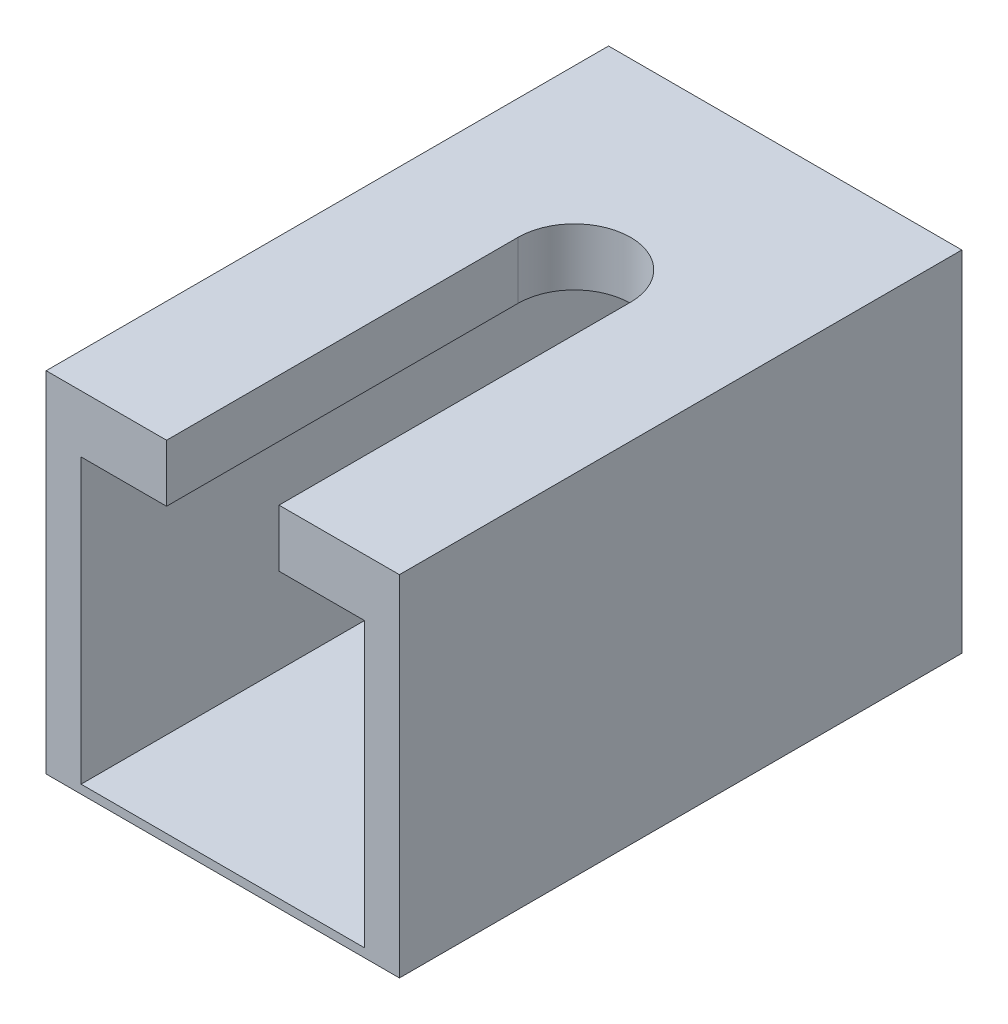
from build123d import *

# Parameters (mm, degrees)
SKETCH1_W           = 15.95500004
SKETCH1_H           = 15.775635
SKETCH1_W_2         = 12.8
SKETCH1_H_2         = 12.8
BOSS_EXTRUDE1_DEPTH = 12.7
CUT_EXTRUDE1_DEPTH  = 12.7


with BuildPart() as part:
    # Sketch1 → Boss-Extrude1 (new body, symmetric)
    with BuildSketch(Plane.XY):
        with Locations((0, 1.0956925)):
            Rectangle(SKETCH1_W, SKETCH1_H)
        Rectangle(SKETCH1_W_2, SKETCH1_H_2, mode=Mode.SUBTRACT)
    extrude(amount=BOSS_EXTRUDE1_DEPTH, both=True)

    # Sketch2 → Cut-Extrude1 (cut)
    with BuildSketch(Plane(origin=(0, 8.98351, 0), x_dir=(1, 0, 0), z_dir=(0, 1, 0))):
        with BuildLine():
            Line((2.54, 3.175), (2.54, -12.7))
            Line((2.54, -12.7), (-2.54, -12.7))
            Line((-2.54, -12.7), (-2.54, 3.175))
            ThreePointArc((-2.54, 3.175), (0, 5.715), (2.54, 3.175))
        make_face()
    extrude(amount=-CUT_EXTRUDE1_DEPTH, mode=Mode.SUBTRACT)


solid = part.part
